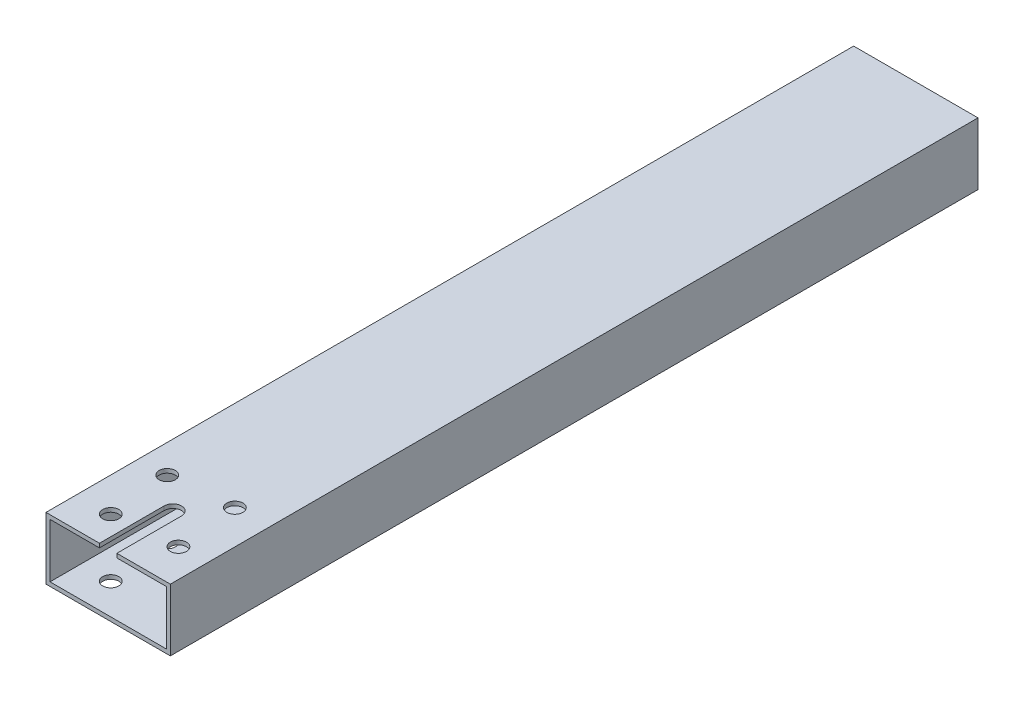
from build123d import *

# Parameters (mm, degrees)
SKETCH1_W           = 50.8
SKETCH1_H           = 25.4
SKETCH1_W_2         = 47.498
SKETCH1_H_2         = 22.098
BOSS_EXTRUDE1_DEPTH = 330
SKETCH2_R           = 3.300000004
CUT_EXTRUDE2_DEPTH  = 26.4
CUT_EXTRUDE3_DEPTH  = 8.89


with BuildPart() as part:
    # Sketch1 → Boss-Extrude1 (new body)
    with BuildSketch(Plane.XY):
        with Locations((11.394392523, 4.86635514)):
            Rectangle(SKETCH1_W, SKETCH1_H)
        with Locations((11.394392523, 4.86635514)):
            Rectangle(SKETCH1_W_2, SKETCH1_H_2, mode=Mode.SUBTRACT)
    extrude(amount=BOSS_EXTRUDE1_DEPTH)

    # Sketch2 → Cut-Extrude2 (cut, through all)
    with BuildSketch(Plane(origin=(0, 17.56635514, 0), x_dir=(1, 0, 0), z_dir=(0, 1, 0))):
        with Locations((-2.423312001, -292.04835777)):
            Circle(SKETCH2_R)
        with Locations((22.930034754, -289.766295475)):
            Circle(SKETCH2_R)
        with Locations((25.212097048, -315.11964223)):
            Circle(SKETCH2_R)
        with Locations((-0.141249707, -317.401704525)):
            Circle(SKETCH2_R)
    extrude(amount=-CUT_EXTRUDE2_DEPTH, mode=Mode.SUBTRACT)

    # Sketch4 → Cut-Extrude3 (cut)
    with BuildSketch(Plane(origin=(0, 17.56635514, 0), x_dir=(1, 0, 0), z_dir=(0, 1, 0))):
        with BuildLine():
            ThreePointArc((14.950392523, -303.584), (11.394392523, -300.028), (7.838392523, -303.584))
            Line((7.838392523, -303.584), (7.838392523, -330))
            Line((7.838392523, -330), (14.950392523, -330))
            Line((14.950392523, -330), (14.950392523, -303.584))
        make_face()
    extrude(amount=-CUT_EXTRUDE3_DEPTH, mode=Mode.SUBTRACT)


solid = part.part
